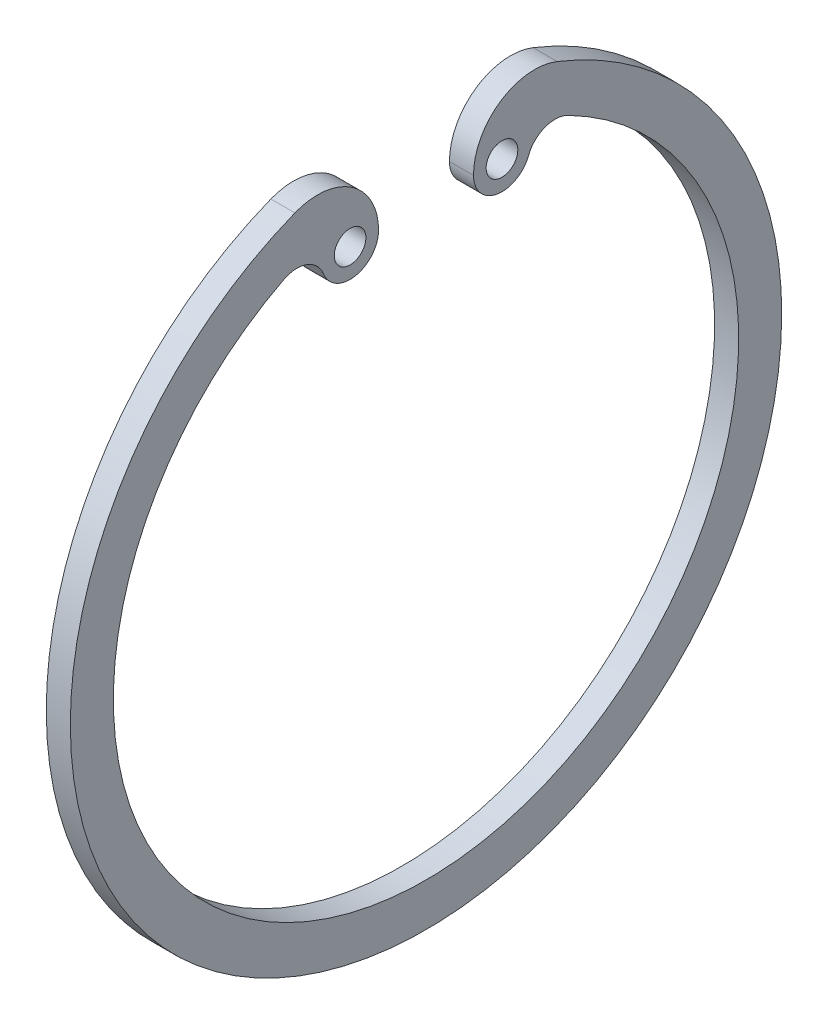
from build123d import *

# Parameters (mm, degrees)
SKETCH_1_R      = 1.25
EXTRUDE_1_DEPTH = 1.9


with BuildPart() as part:
    # Эскиз1 → Бобышка-Вытянуть1 (new body)
    with BuildSketch(Plane(origin=(0, 0, 0), x_dir=(0, 0, -1), z_dir=(1, 0, 0))):
        with BuildLine():
            ThreePointArc((-10.357624838, 26.121439618), (0, -28.1), (10.357624838, 26.121439618))
            ThreePointArc((10.357624838, 26.121439618), (5.865289545, 25.627220585), (3.75, 21.633365434))
            ThreePointArc((3.75, 21.633365434), (5.585080517, 19.421953708), (8.096970509, 20.817758491))
            ThreePointArc((8.096970509, 20.817758491), (9.392356028, 22.104521997), (11.215605485, 22.006821525))
            ThreePointArc((11.215605485, 22.006821525), (0, -24.7), (-11.215605485, 22.006821525))
            ThreePointArc((-11.215605485, 22.006821525), (-9.392356028, 22.104521997), (-8.096970509, 20.817758491))
            ThreePointArc((-8.096970509, 20.817758491), (-5.585080517, 19.421953708), (-3.75, 21.633365434))
            ThreePointArc((-3.75, 21.633365434), (-5.865289545, 25.627220585), (-10.357624838, 26.121439618))
        make_face()
        with Locations((-6, 21.633365434)):
            Circle(SKETCH_1_R, mode=Mode.SUBTRACT)
        with Locations((6, 21.633365434)):
            Circle(SKETCH_1_R, mode=Mode.SUBTRACT)
    extrude(amount=EXTRUDE_1_DEPTH)


solid = part.part
